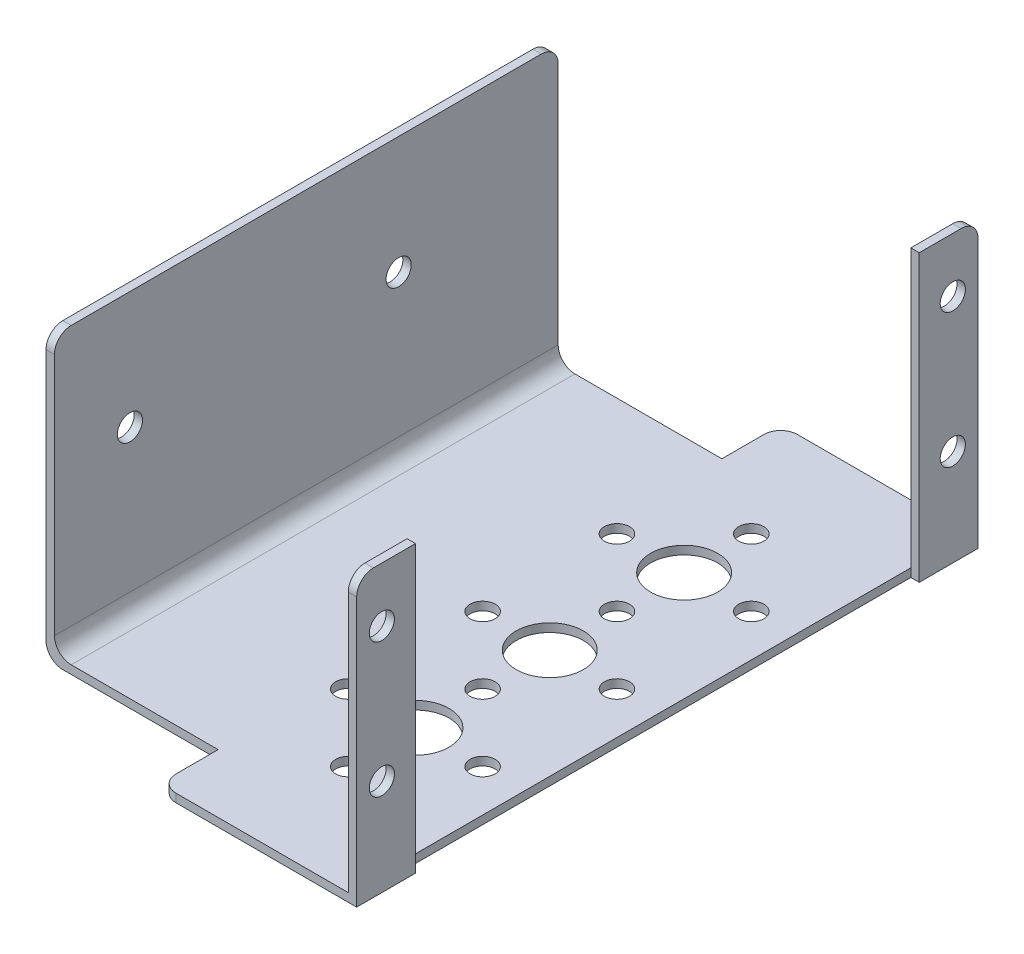
from build123d import *

# Parameters (mm, degrees)
BOSS_EXTRUDE1_DEPTH = 74
SKETCH2_R           = 1.5
CUT_EXTRUDE1_DEPTH  = 1
SKETCH4_W           = 60
SKETCH4_H           = 34
CUT_EXTRUDE2_DEPTH  = 1
SKETCH6_W           = 7
SKETCH6_H           = 34
CUT_EXTRUDE3_DEPTH  = 1
SKETCH7_R           = 1.5
CUT_EXTRUDE4_DEPTH  = 1
SKETCH8_R           = 4
SKETCH8_R_2         = 1.5
CUT_EXTRUDE5_DEPTH  = 1
SKETCH9_W           = 19.5
SKETCH9_H           = 7
CUT_EXTRUDE6_DEPTH  = 1
FILLET1_R           = 2


with BuildPart() as part:
    # Sketch1 → Boss-Extrude1 (new body)
    with BuildSketch(Plane.XY):
        Polygon((-68.212386303, 4.586111111), (-68.212386303, -28.413888889), (-26.212386303, -28.413888889), (-26.212386303, 4.586111111), (-25.212386303, 4.586111111), (-25.212386303, -29.413888889), (-69.212386303, -29.413888889), (-69.212386303, 4.586111111), align=None)
    extrude(amount=BOSS_EXTRUDE1_DEPTH)

    # Sketch2 → Cut-Extrude1 (cut)
    with BuildSketch(Plane(origin=(-25.212386303, 0, 0), x_dir=(0, 0, -1), z_dir=(1, 0, 0))):
        with Locations((-3, -1.913888889)):
            Circle(SKETCH2_R)
        with Locations((-71, -1.913888889)):
            Circle(SKETCH2_R)
        with Locations((-71, -17.913888889)):
            Circle(SKETCH2_R)
        with Locations((-3, -17.913888889)):
            Circle(SKETCH2_R)
    extrude(amount=-CUT_EXTRUDE1_DEPTH, mode=Mode.SUBTRACT)

    # Sketch4 → Cut-Extrude2 (cut)
    with BuildSketch(Plane(origin=(-25.212386303, 0, 0), x_dir=(0, 0, -1), z_dir=(1, 0, 0))):
        with Locations((-37, -12.413888889)):
            Rectangle(SKETCH4_W, SKETCH4_H)
    extrude(amount=-CUT_EXTRUDE2_DEPTH, mode=Mode.SUBTRACT)

    # Sketch6 → Cut-Extrude3 (cut)
    with BuildSketch(Plane.ZY.offset(69.212386303)):
        with Locations((3.5, -12.413888889)):
            Rectangle(SKETCH6_W, SKETCH6_H)
        with Locations((70.5, -12.413888889)):
            Rectangle(SKETCH6_W, SKETCH6_H)
    extrude(amount=-CUT_EXTRUDE3_DEPTH, mode=Mode.SUBTRACT)

    # Sketch7 → Cut-Extrude4 (cut)
    with BuildSketch(Plane.ZY.offset(69.212386303)):
        with Locations((58, -9.413888889)):
            Circle(SKETCH7_R)
        with Locations((26, -9.413888889)):
            Circle(SKETCH7_R)
    extrude(amount=-CUT_EXTRUDE4_DEPTH, mode=Mode.SUBTRACT)

    # Sketch8 → Cut-Extrude5 (cut)
    with BuildSketch(Plane(origin=(0, -29.413888889, 0), x_dir=(-1, 0, 0), z_dir=(0, -1, 0))):
        with Locations((39.212386303, -37)):
            Circle(SKETCH8_R)
        with Locations((39.212386303, -29)):
            Circle(SKETCH8_R_2)
        with Locations((47.212386303, -37)):
            Circle(SKETCH8_R_2)
        with Locations((39.212386303, -45)):
            Circle(SKETCH8_R_2)
        with Locations((31.212386303, -37)):
            Circle(SKETCH8_R_2)
        with Locations((31.212386303, -21)):
            Circle(SKETCH8_R_2)
        with Locations((39.212386303, -13)):
            Circle(SKETCH8_R_2)
        with Locations((47.212386303, -21)):
            Circle(SKETCH8_R_2)
        with Locations((39.212386303, -21)):
            Circle(SKETCH8_R)
        with Locations((39.212386303, -61)):
            Circle(SKETCH8_R_2)
        with Locations((39.212386303, -53)):
            Circle(SKETCH8_R)
        with Locations((47.212386303, -53)):
            Circle(SKETCH8_R_2)
        with Locations((31.212386303, -53)):
            Circle(SKETCH8_R_2)
    extrude(amount=-CUT_EXTRUDE5_DEPTH, mode=Mode.SUBTRACT)

    # Sketch9 → Cut-Extrude6 (cut)
    with BuildSketch(Plane.XZ.offset(29.413888889)):
        with Locations((-58.462386303, 3.5)):
            Rectangle(SKETCH9_W, SKETCH9_H)
        with Locations((-58.462386303, 70.5)):
            Rectangle(SKETCH9_W, SKETCH9_H)
    extrude(amount=-CUT_EXTRUDE6_DEPTH, mode=Mode.SUBTRACT)

    # Fillet1
    fillet1_edges = [part.edges().sort_by_distance(p)[0] for p in [
        (-48.712386303, -28.913888889, 0),
        (-25.712386303, 4.586111111, 74),
        (-48.712386303, -28.913888889, 74),
        (-68.712386303, 4.586111111, 7),
        (-68.212386303, -28.413888889, 37),
        (-69.212386303, -29.413888889, 37),
        (-68.712386303, 4.586111111, 67),
        (-25.712386303, 4.586111111, 0),
    ]]
    fillet(fillet1_edges, radius=FILLET1_R)


solid = part.part
